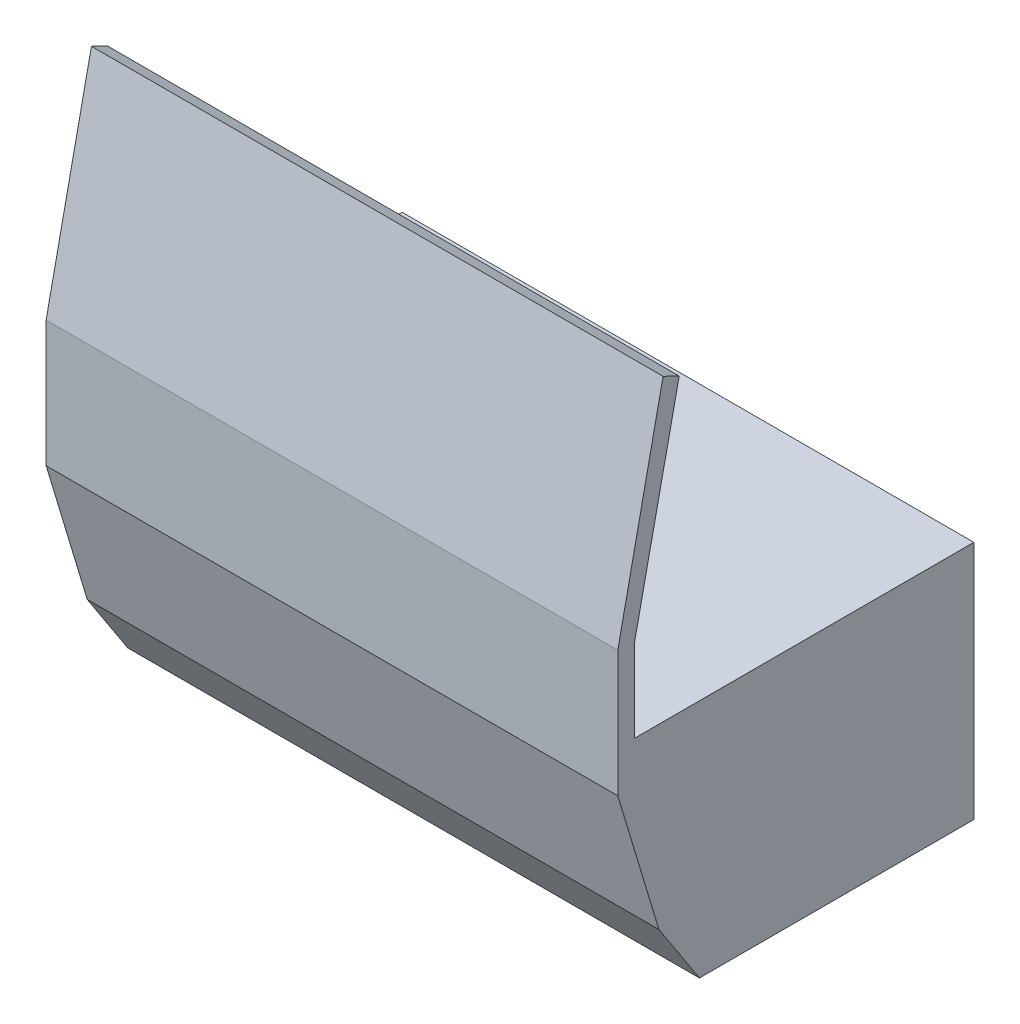
from build123d import *

# Parameters (mm, degrees)
SKETCH1_W           = 2500
SKETCH1_H           = 1050
BOSS_EXTRUDE1_DEPTH = 1200
SHELL2_T            = -20
BOSS_EXTRUDE2_DEPTH = 2500


with BuildPart() as part:
    # Sketch1 → Boss-Extrude1 (new body)
    with BuildSketch(Plane.XY):
        with Locations((-1250, 525)):
            Rectangle(SKETCH1_W, SKETCH1_H)
    extrude(amount=BOSS_EXTRUDE1_DEPTH)

    # Shell2
    shell2_openings = [part.faces().sort_by_distance(p)[0] for p in [
        (-1250, 525, 1200),
        (-1250, 0, 600),
    ]]
    offset(amount=SHELL2_T, openings=shell2_openings, kind=Kind.INTERSECTION)

    # Sketch2 → Boss-Extrude2 (add)
    with BuildSketch(Plane(origin=(0, 0, 0), x_dir=(0, 0, -1), z_dir=(1, 0, 0))):
        Polygon((-1200, 1050), (-1483.973725, 1050), (-1483.973725, 1412.881782165), (-1288.623152026, 2324.113117687), (-1359.145547993, 2358.393756698), (-1557.190049739, 1420.527840387), (-1557.190049739, 1050), (-1557.190049739, 868.710221607), (-1377.246304053, 272.141248376), (-1200, 0), align=None)
    extrude(amount=-BOSS_EXTRUDE2_DEPTH)


solid = part.part
